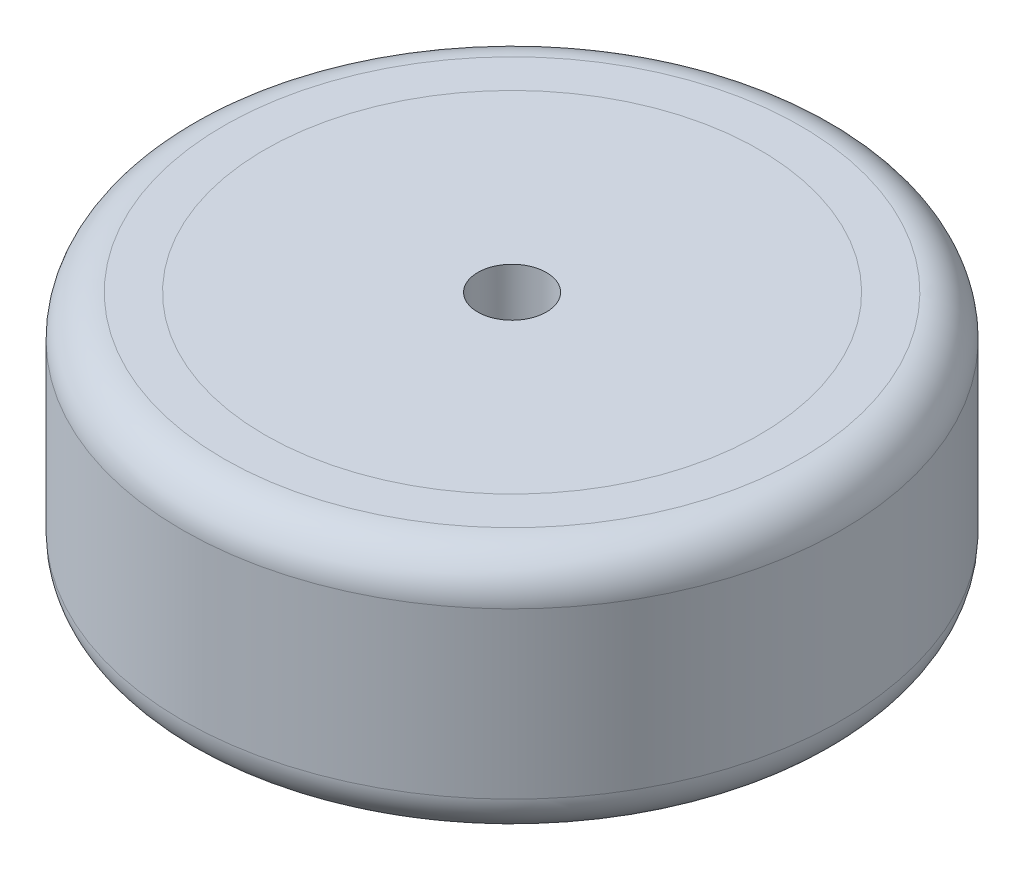
from build123d import *

# Parameters (mm, degrees)
SKETCH1_R           = 24
BOSS_EXTRUDE1_DEPTH = 18
SKETCH2_R           = 18
CUT_EXTRUDE1_DEPTH  = 5
SKETCH3_R           = 18
CUT_EXTRUDE2_DEPTH  = 5
SKETCH4_R           = 18
BOSS_EXTRUDE2_DEPTH = 5
SKETCH5_R           = 18
BOSS_EXTRUDE3_DEPTH = 5
SKETCH6_R           = 2.5
CUT_EXTRUDE3_DEPTH  = 19
FILLET1_R           = 3


with BuildPart() as part:
    # Sketch1 → Boss-Extrude1 (new body)
    with BuildSketch(Plane(origin=(0, 0, 0), x_dir=(1, 0, 0), z_dir=(0, 1, 0))):
        Circle(SKETCH1_R)
    extrude(amount=BOSS_EXTRUDE1_DEPTH)

    # Sketch2 → Cut-Extrude1 (cut)
    with BuildSketch(Plane(origin=(0, 18, 0), x_dir=(1, 0, 0), z_dir=(0, 1, 0))):
        Circle(SKETCH2_R)
    extrude(amount=-CUT_EXTRUDE1_DEPTH, mode=Mode.SUBTRACT)

    # Sketch3 → Cut-Extrude2 (cut)
    with BuildSketch(Plane.XZ):
        Circle(SKETCH3_R)
    extrude(amount=-CUT_EXTRUDE2_DEPTH, mode=Mode.SUBTRACT)


with BuildPart() as body_2:
    # Sketch4 → Boss-Extrude2 (new body)
    with BuildSketch(Plane(origin=(0, 13, 0), x_dir=(1, 0, 0), z_dir=(0, 1, 0))):
        Circle(SKETCH4_R)
    extrude(amount=BOSS_EXTRUDE2_DEPTH)


with BuildPart() as body_3:
    # Sketch5 → Boss-Extrude3 (new body)
    with BuildSketch(Plane.XZ.offset(-5)):
        Circle(SKETCH5_R)
    extrude(amount=BOSS_EXTRUDE3_DEPTH)


with BuildPart() as cut_extrude3_tool:
    # Sketch6 → Cut-Extrude3 (new body, through all)
    with BuildSketch(Plane(origin=(0, 0, 0), x_dir=(-1, 0, 0), z_dir=(0, -1, 0))):
        Circle(SKETCH6_R)
    extrude(amount=-CUT_EXTRUDE3_DEPTH)


with BuildPart() as part_1:
    add(part.part)

    # Cut-Extrude3: cut by cut_extrude3_tool
    add(cut_extrude3_tool.part, mode=Mode.SUBTRACT)

    # Fillet1
    fillet1_edges = [part_1.edges().sort_by_distance(p)[0] for p in [
        (-24, 0, 0),
        (-24, 18, 0),
    ]]
    fillet(fillet1_edges, radius=FILLET1_R)


with BuildPart() as body_2_1:
    add(body_2.part)

    # Cut-Extrude3: cut by cut_extrude3_tool
    add(cut_extrude3_tool.part, mode=Mode.SUBTRACT)


with BuildPart() as body_3_1:
    add(body_3.part)

    # Cut-Extrude3: cut by cut_extrude3_tool
    add(cut_extrude3_tool.part, mode=Mode.SUBTRACT)


solid = Compound([part_1.part, body_2_1.part, body_3_1.part])
